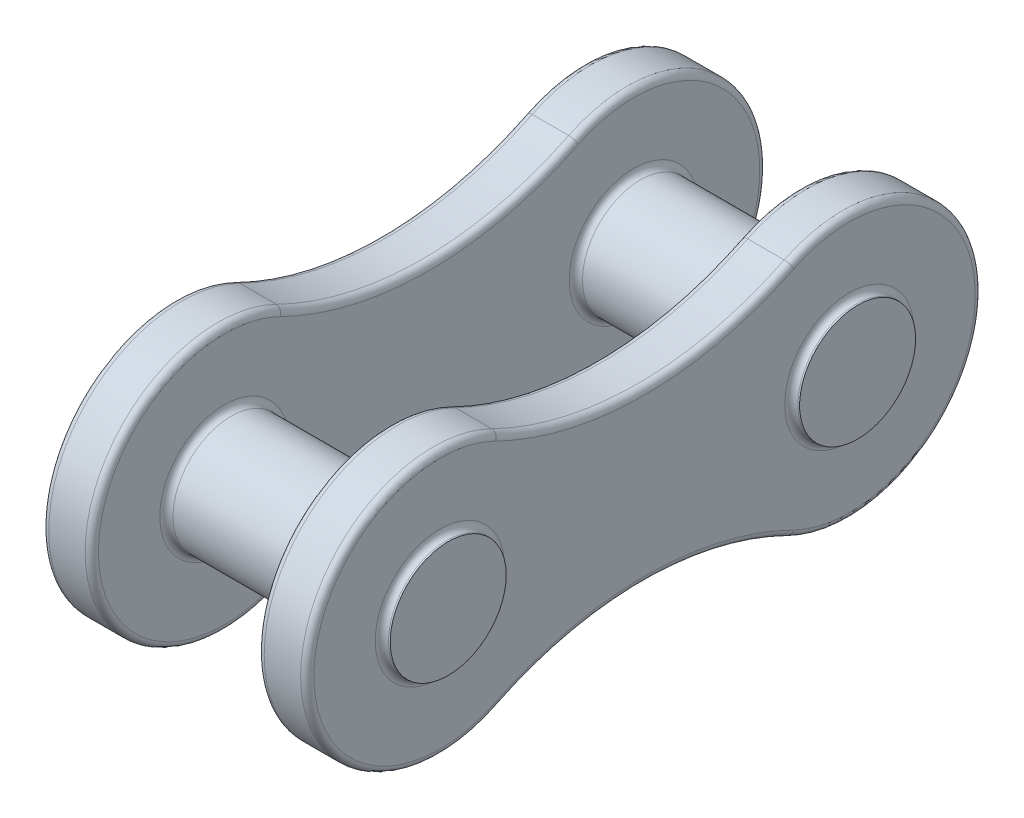
from build123d import *

# Parameters (mm, degrees)
SALIENTE_EXTRUIR1_START = 2.5
CROQUIS1_R              = 1.75
SALIENTE_EXTRUIR1_DEPTH = 1.5
SALIENTE_EXTRUIR2_START = -2.5
CROQUIS2_R              = 1.75
SALIENTE_EXTRUIR2_DEPTH = 1.5
CROQUIS3_R              = 1.75
SALIENTE_EXTRUIR3_DEPTH = 4.25
REDONDEO1_R             = 0.2


with BuildPart() as part:
    # Croquis1 → Saliente-Extruir1 (new body)
    with BuildSketch(Plane(origin=(0, 0, 0), x_dir=(0, 0, -1), z_dir=(1, 0, 0)).offset(SALIENTE_EXTRUIR1_START)):
        with BuildLine():
            ThreePointArc((-4.410714286, 3.589888009), (-10.175, 0), (-4.410714286, -3.589888009))
            ThreePointArc((-4.410714286, -3.589888009), (0, -2.564608032), (4.410714286, -3.589888009))
            ThreePointArc((4.410714286, -3.589888009), (10.175, 0), (4.410714286, 3.589888009))
            ThreePointArc((4.410714286, 3.589888009), (0, 2.564608032), (-4.410714286, 3.589888009))
        make_face()
        with Locations((-6.175, 0)):
            Circle(CROQUIS1_R, mode=Mode.SUBTRACT)
        with Locations((6.175, 0)):
            Circle(CROQUIS1_R, mode=Mode.SUBTRACT)
    extrude(amount=SALIENTE_EXTRUIR1_DEPTH)



with BuildPart() as body_2:
    # Croquis2 → Saliente-Extruir2 (new body)
    with BuildSketch(Plane(origin=(0, 0, 0), x_dir=(0, 0, -1), z_dir=(1, 0, 0)).offset(SALIENTE_EXTRUIR2_START)):
        with BuildLine():
            ThreePointArc((-4.410714286, 3.589888009), (0, 2.564608032), (4.410714286, 3.589888009))
            ThreePointArc((4.410714286, 3.589888009), (10.175, 0), (4.410714286, -3.589888009))
            ThreePointArc((4.410714286, -3.589888009), (0, -2.564608032), (-4.410714286, -3.589888009))
            ThreePointArc((-4.410714286, -3.589888009), (-10.175, 0), (-4.410714286, 3.589888009))
        make_face()
        with Locations((6.175, 0)):
            Circle(CROQUIS2_R, mode=Mode.SUBTRACT)
        with Locations((-6.175, 0)):
            Circle(CROQUIS2_R, mode=Mode.SUBTRACT)
    extrude(amount=-SALIENTE_EXTRUIR2_DEPTH)


with BuildPart() as part_1:
    add(part.part)

    add(body_2.part)  # Saliente-Extruir3 merges body 2
    # Croquis3 → Saliente-Extruir3 (add, symmetric)
    with BuildSketch(Plane(origin=(0, 0, 0), x_dir=(0, 0, -1), z_dir=(1, 0, 0))):
        with Locations((6.175, 0)):
            Circle(CROQUIS3_R)
        with Locations((-6.175, 0)):
            Circle(CROQUIS3_R)
    extrude(amount=SALIENTE_EXTRUIR3_DEPTH, both=True)

    # Redondeo1
    redondeo1_edges = [part_1.edges().sort_by_distance(p)[0] for p in [
        (4, 0, 7.925),
        (4, -2.564608032, 0),
        (4, 0, -4.425),
        (4, 0, -10.175),
        (2.5, 0, -4.425),
        (-4, 0, -4.425),
        (-4, 0, 10.175),
        (-4, 2.564608032, 0),
        (-4, 0, -10.175),
        (-4, -2.564608032, 0),
        (-2.5, 0, 10.175),
        (-2.5, -2.564608032, 0),
        (-2.5, 0, -10.175),
        (-2.5, 2.564608032, 0),
        (-2.5, 0, -4.425),
        (-2.5, 0, 7.925),
        (2.5, 0, 7.925),
        (-4, 0, 7.925),
        (4, 2.564608032, 0),
        (2.5, 0, -10.175),
        (2.5, -2.564608032, 0),
        (2.5, 0, 10.175),
        (2.5, 2.564608032, 0),
        (4, 0, 10.175),
    ]]
    fillet(redondeo1_edges, radius=REDONDEO1_R)


solid = part_1.part
